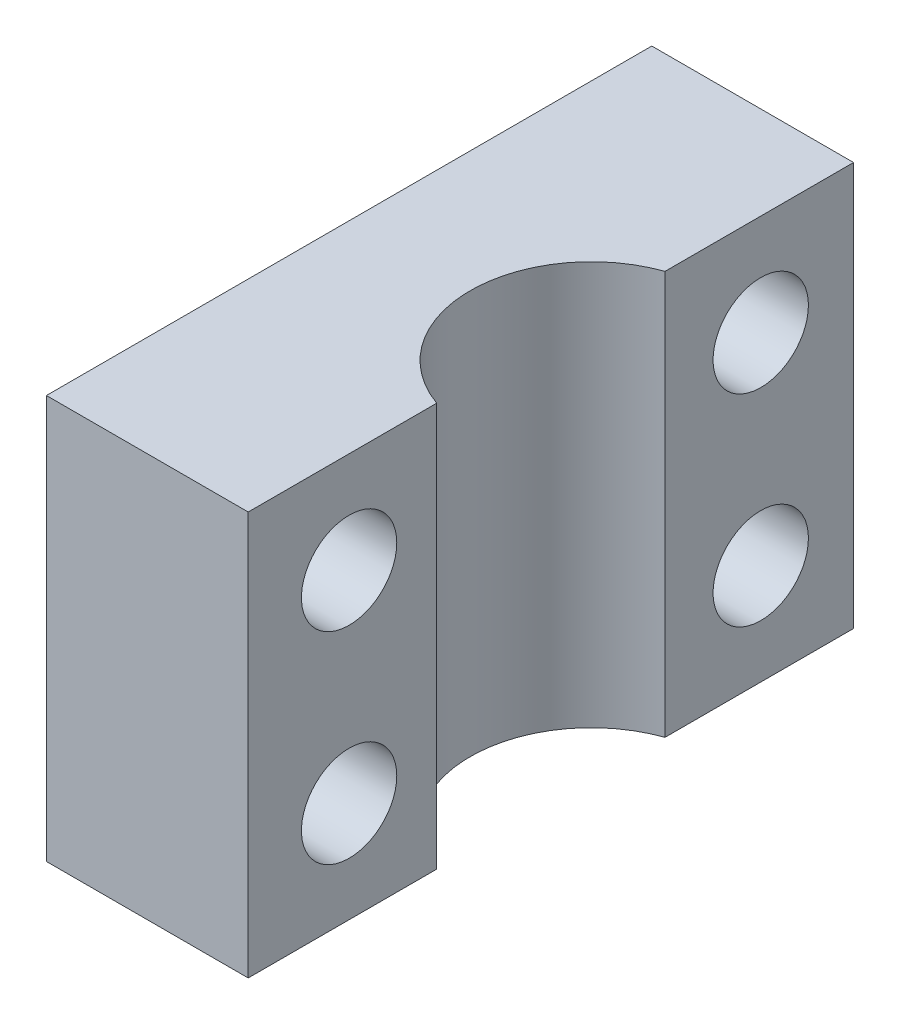
from build123d import *

# Parameters (mm, degrees)
SKETCH1_W           = 12.7
SKETCH1_H           = 19.05
BOSS_EXTRUDE1_DEPTH = 12.7
CUT_EXTRUDE2_DEPTH  = 12.7
SKETCH5_R           = 1.5
CUT_EXTRUDE3_DEPTH  = 12.7
CUT_EXTRUDE4_DEPTH  = 12.7
SKETCH7_W           = 12.213119959
SKETCH7_H           = 9.608468088
CUT_EXTRUDE5_DEPTH  = 12.7


with BuildPart() as part:
    # Sketch1 → Boss-Extrude1 (new body)
    with BuildSketch(Plane(origin=(0, 0, 0), x_dir=(1, 0, 0), z_dir=(0, 1, 0))):
        with Locations((6.35, 9.525)):
            Rectangle(SKETCH1_W, SKETCH1_H)
    extrude(amount=BOSS_EXTRUDE1_DEPTH)

    # Sketch4 → Cut-Extrude2 (cut)
    with BuildSketch(Plane(origin=(0, 12.7, 0), x_dir=(1, 0, 0), z_dir=(0, 1, 0))):
        Polygon((0, 19.05), (0, 9.525), (6.35, 19.05), align=None)
        Polygon((6.35, 0), (0, 9.525), (0, 0), align=None)
        with BuildLine():
            Line((12.7, 5.932897552), (12.7, 13.117102448))
            ThreePointArc((12.7, 13.117102448), (10.16, 9.525), (12.7, 5.932897552))
        make_face()
        with BuildLine():
            ThreePointArc((17.78, 9.525), (16.169704526, 12.635851973), (12.7, 13.117102448))
            Line((12.7, 13.117102448), (12.7, 5.932897552))
            ThreePointArc((12.7, 5.932897552), (16.169704526, 6.414148027), (17.78, 9.525))
        make_face()
    extrude(amount=-CUT_EXTRUDE2_DEPTH, mode=Mode.SUBTRACT)

    # Sketch5 → Cut-Extrude3 (cut)
    with BuildSketch(Plane(origin=(12.7, 0, 0), x_dir=(0, 0, -1), z_dir=(1, 0, 0))):
        with Locations((3.175, 9.525)):
            Circle(SKETCH5_R)
        with Locations((16.129, 9.525)):
            Circle(SKETCH5_R)
        with Locations((16.129, 3.175)):
            Circle(SKETCH5_R)
        with Locations((3.175, 3.175)):
            Circle(SKETCH5_R)
    extrude(amount=-CUT_EXTRUDE3_DEPTH, mode=Mode.SUBTRACT)

    # Sketch6 → Cut-Extrude4 (cut)
    with BuildSketch(Plane.XZ):
        Polygon((6.35, 0), (6.35, -5.570300529), (2.636466314, -5.570300529), align=None)
    cut_extrude4 = extrude(amount=-CUT_EXTRUDE4_DEPTH, mode=Mode.SUBTRACT)

    # Mirror1: Cut-Extrude4 across plane
    add(cut_extrude4.mirror(Plane(origin=(0, 0, -9.525), x_dir=(1, 0, 0), z_dir=(0, 0, -1))), mode=Mode.SUBTRACT)

    # Sketch7 → Cut-Extrude5 (cut)
    with BuildSketch(Plane.XZ):
        with Locations((0.243440021, -8.675465427)):
            Rectangle(SKETCH7_W, SKETCH7_H)
    extrude(amount=-CUT_EXTRUDE5_DEPTH, mode=Mode.SUBTRACT)


solid = part.part
